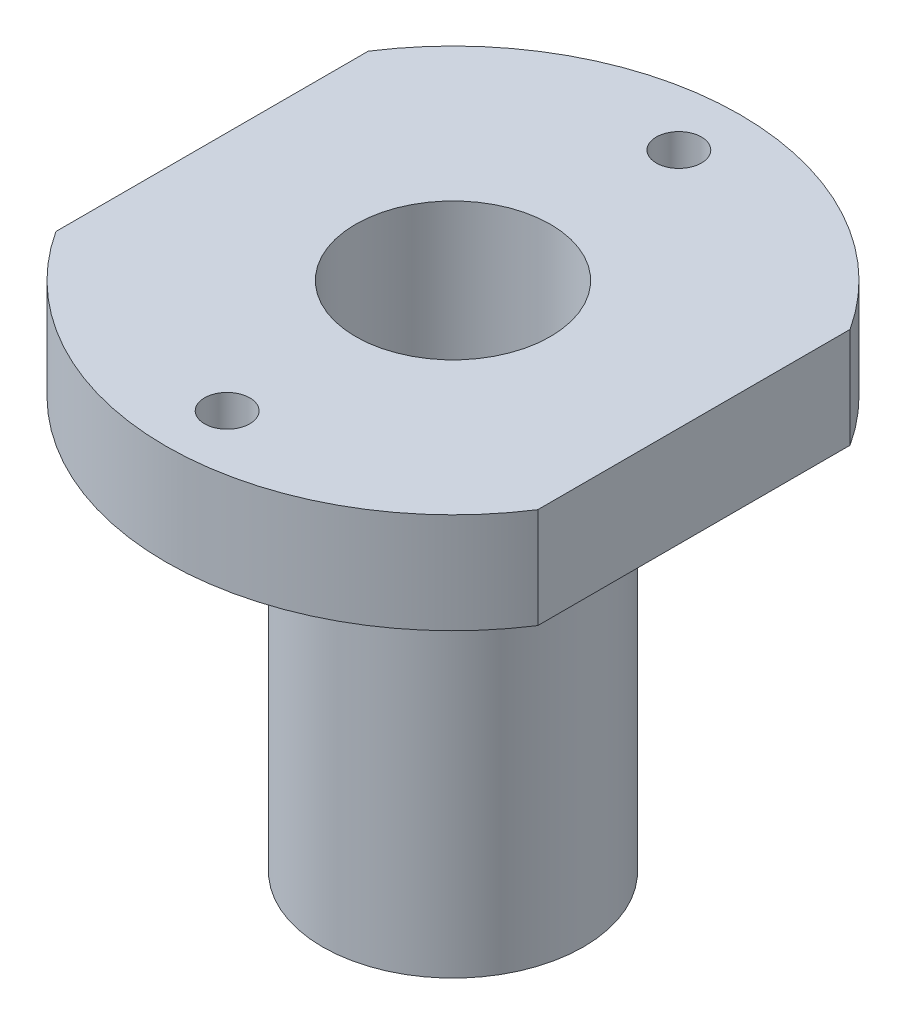
from build123d import *

# Parameters (mm, degrees)
SKETCH1_R           = 14.3
BOSS_EXTRUDE1_DEPTH = 5
SKETCH2_R           = 6.5
BOSS_EXTRUDE2_DEPTH = 20.5
SKETCH5_R           = 1.125
CUT_EXTRUDE1_DEPTH  = 15
SKETCH6_R           = 4.85
CUT_EXTRUDE2_DEPTH  = 25.5
SKETCH7_W           = 3.263473237
SKETCH7_H           = 32.347337023
SKETCH7_W_2         = 3.52826165
CUT_EXTRUDE5_DEPTH  = 10


with BuildPart() as part:
    # Sketch1 → Boss-Extrude1 (new body)
    with BuildSketch(Plane(origin=(0, 0, 0), x_dir=(1, 0, 0), z_dir=(0, 1, 0))):
        Circle(SKETCH1_R)
    extrude(amount=BOSS_EXTRUDE1_DEPTH)

    # Sketch2 → Boss-Extrude2 (add)
    with BuildSketch(Plane.XZ):
        Circle(SKETCH2_R)
    extrude(amount=BOSS_EXTRUDE2_DEPTH)

    # Sketch5 → Cut-Extrude1 (cut)
    with BuildSketch(Plane(origin=(0, 5, 0), x_dir=(1, 0, 0), z_dir=(0, 1, 0))):
        with Locations((0, -11.25)):
            Circle(SKETCH5_R)
        with Locations((0, 11.25)):
            Circle(SKETCH5_R)
    extrude(amount=-CUT_EXTRUDE1_DEPTH, mode=Mode.SUBTRACT)

    # Sketch6 → Cut-Extrude2 (cut)
    with BuildSketch(Plane.XZ.offset(20.5)):
        Circle(SKETCH6_R)
    extrude(amount=-CUT_EXTRUDE2_DEPTH, mode=Mode.SUBTRACT)

    # Sketch7 → Cut-Extrude5 (cut)
    with BuildSketch(Plane(origin=(0, 5, 0), x_dir=(1, 0, 0), z_dir=(0, 1, 0))):
        with Locations((13.631736618, 0.768402462)):
            Rectangle(SKETCH7_W, SKETCH7_H)
        with Locations((-13.764130825, 0.768402462)):
            Rectangle(SKETCH7_W_2, SKETCH7_H)
    extrude(amount=-CUT_EXTRUDE5_DEPTH, mode=Mode.SUBTRACT)


solid = part.part
